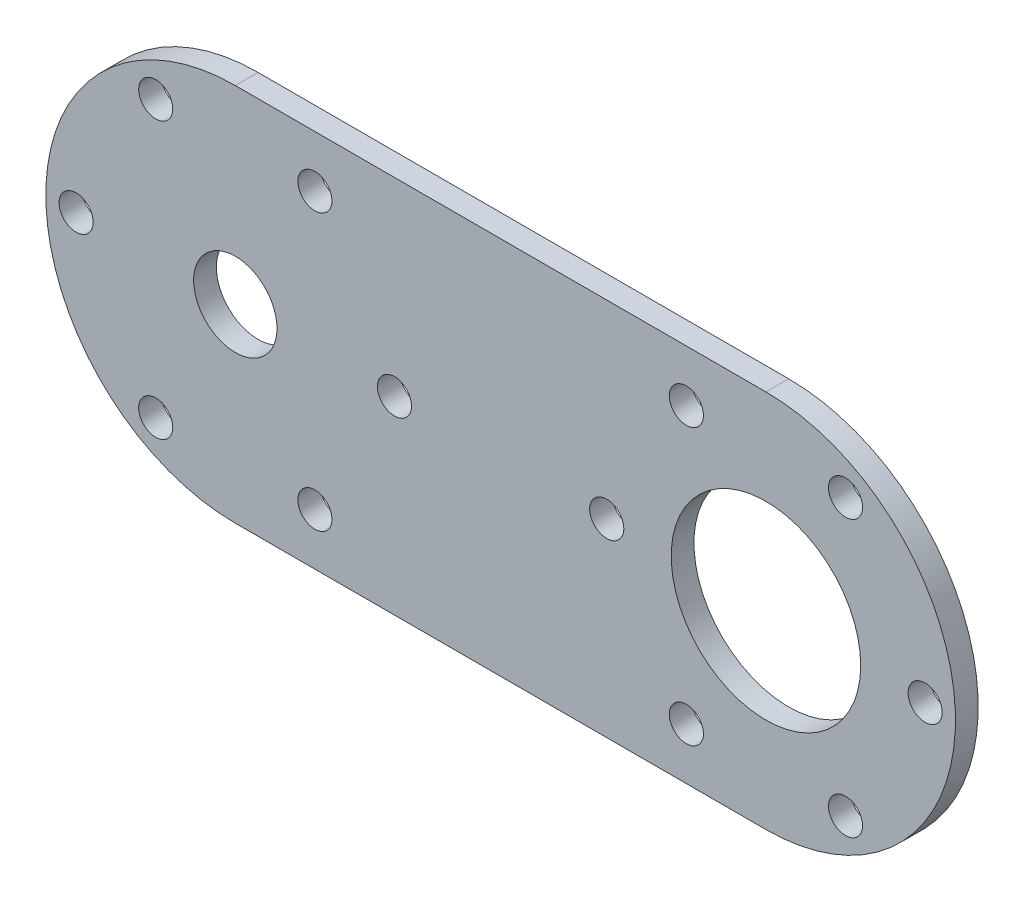
from build123d import *

# Parameters (mm, degrees)
CROQUIS1_R                    = 12.5
SALIENTE_EXTRUIR1_DEPTH       = 3
TALADRO_DE_MARGEN_PARA_M42_D  = 4.5
TALADRO_DE_MARGEN_PARA_M101_D = 11


with BuildPart() as part:
    # Croquis1 → Saliente-Extruir1 (new body)
    with BuildSketch(Plane.XY):
        with BuildLine():
            Line((70, 25), (0, 25))
            ThreePointArc((0, 25), (-25, 0), (0, -25))
            Line((0, -25), (70, -25))
            ThreePointArc((70, -25), (95, 0), (70, 25))
        make_face()
        with Locations((70, 0)):
            Circle(CROQUIS1_R, mode=Mode.SUBTRACT)
    extrude(amount=SALIENTE_EXTRUIR1_DEPTH)

    # Taladro de margen para M42 (through all)
    with Locations(Plane.XY.offset(3)):
        with Locations((-21, 0), (91, 0), (-10.5, 18.186533479), (10.5, 18.186533479), (21, 0), (10.5, -18.186533479), (-10.5, -18.186533479), (80.5, -18.186533479), (59.5, -18.186533479), (49, 0), (59.5, 18.186533479), (80.5, 18.186533479)):
            Hole(TALADRO_DE_MARGEN_PARA_M42_D / 2)

    # Taladro de margen para M101 (through all)
    with Locations(Plane.XY.offset(3)):
        with Locations((0, 0)):
            Hole(TALADRO_DE_MARGEN_PARA_M101_D / 2)


solid = part.part
